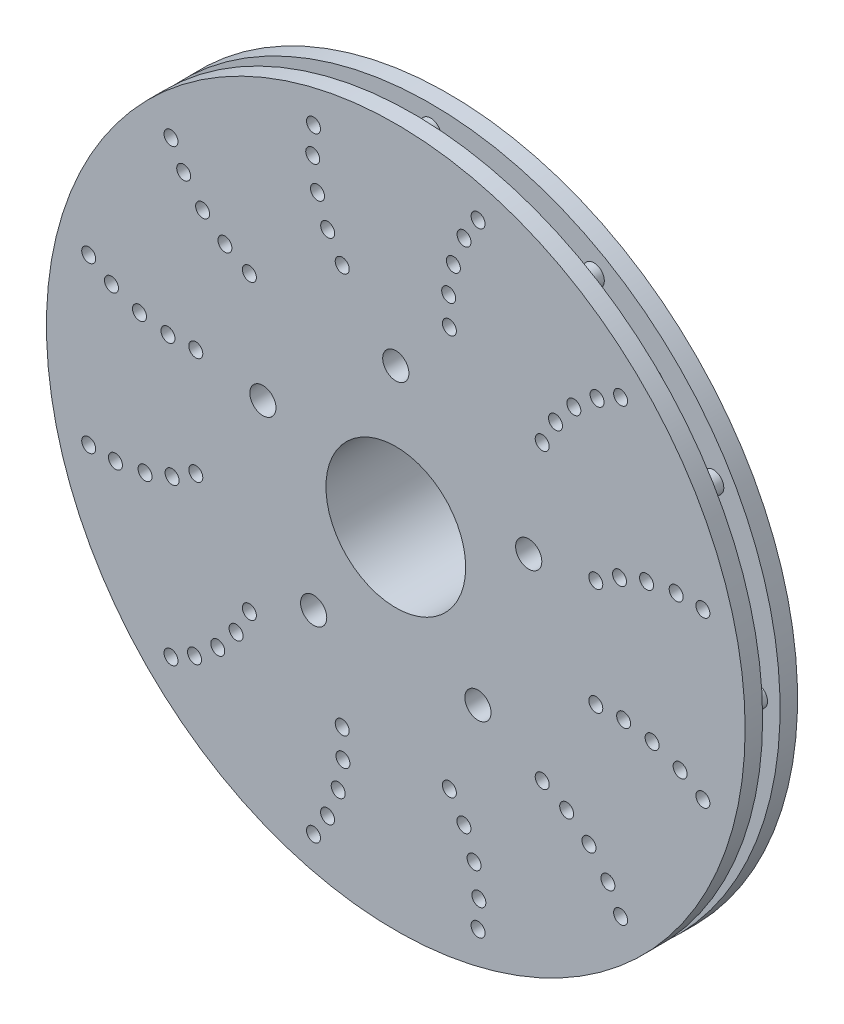
from build123d import *

# Parameters (mm, degrees)
SKETCH2_R           = 60.325
SKETCH2_R_2         = 25.4
SKETCH2_R_3         = 4.7625
BOSS_EXTRUDE1_DEPTH = 50.8
SKETCH4_R           = 127
SKETCH4_R_2         = 60.325
BOSS_EXTRUDE2_DEPTH = 6.35
BOSS_EXTRUDE3_DEPTH = 6.35
SKETCH6_R           = 127
SKETCH6_R_2         = 66.675
BOSS_EXTRUDE4_DEPTH = 6.35
SKETCH7_R           = 2.54
CUT_EXTRUDE1_DEPTH  = 84.836


with BuildPart() as part:
    # Sketch2 → Boss-Extrude1 (new body)
    with BuildSketch(Plane.XY):
        with Locations((-45.113025794, 24.007516651)):
            Circle(SKETCH2_R)
        with Locations((-45.113025794, 24.007516651)):
            Circle(SKETCH2_R_2, mode=Mode.SUBTRACT)
        with Locations((3.200645234, 39.705579965)):
            Circle(SKETCH2_R_3, mode=Mode.SUBTRACT)
        with Locations((-45.113025794, 74.807516651)):
            Circle(SKETCH2_R_3, mode=Mode.SUBTRACT)
        with Locations((-15.253534977, -17.090546664)):
            Circle(SKETCH2_R_3, mode=Mode.SUBTRACT)
        with Locations((-74.97251661, -17.090546664)):
            Circle(SKETCH2_R_3, mode=Mode.SUBTRACT)
        with Locations((-93.426696822, 39.705579965)):
            Circle(SKETCH2_R_3, mode=Mode.SUBTRACT)
    extrude(amount=BOSS_EXTRUDE1_DEPTH)

    # Sketch4 → Boss-Extrude2 (add)
    with BuildSketch(Plane.XY.offset(50.8)):
        with Locations((-45.113025794, 24.007516651)):
            Circle(SKETCH4_R)
        with Locations((-45.113025794, 24.007516651)):
            Circle(SKETCH4_R_2, mode=Mode.SUBTRACT)
    extrude(amount=-BOSS_EXTRUDE2_DEPTH)

    # Sketch5 → Boss-Extrude3 (add)
    with BuildSketch(Plane(origin=(0, 0, 44.45), x_dir=(-1, 0, 0), z_dir=(0, 0, -1))):
        with BuildLine():
            Line((101.143917866, 128.642816244), (80.279811605, 92.505124145))
            ThreePointArc((80.279811605, 92.505124145), (81.668319408, 87.323142476), (86.850301077, 88.71165028))
            Line((86.850301077, 88.71165028), (107.714407338, 124.849342378))
            ThreePointArc((107.714407338, 124.849342378), (106.325899535, 130.031324047), (101.143917866, 128.642816244))
        make_face()
        with BuildLine():
            Line((48.90649966, 142.639790267), (48.90649966, 100.911577745))
            ThreePointArc((48.90649966, 100.911577745), (45.113025794, 97.118103879), (41.319551928, 100.911577745))
            Line((41.319551928, 100.911577745), (41.319551928, 142.639790267))
            ThreePointArc((41.319551928, 142.639790267), (45.113025794, 146.433264132), (48.90649966, 142.639790267))
        make_face()
        with BuildLine():
            Line((145.954851521, 86.608898195), (109.817159423, 65.744791934))
            ThreePointArc((109.817159423, 65.744791934), (108.428651619, 60.562810265), (113.610633289, 59.174302461))
            Line((113.610633289, 59.174302461), (149.748325387, 80.038408722))
            ThreePointArc((149.748325387, 80.038408722), (151.13683319, 85.220390391), (145.954851521, 86.608898195))
        make_face()
        with BuildLine():
            Line((163.74529941, 27.800990516), (122.017086888, 27.800990516))
            ThreePointArc((122.017086888, 27.800990516), (118.223613022, 24.007516651), (122.017086888, 20.214042785))
            Line((122.017086888, 20.214042785), (163.74529941, 20.214042785))
            ThreePointArc((163.74529941, 20.214042785), (167.538773276, 24.007516651), (163.74529941, 27.800990516))
        make_face()
        with BuildLine():
            Line((149.748325387, -32.023375421), (113.610633289, -11.15926916))
            ThreePointArc((113.610633289, -11.15926916), (108.428651619, -12.547776964), (109.817159423, -17.729758633))
            Line((109.817159423, -17.729758633), (145.954851521, -38.593864894))
            ThreePointArc((145.954851521, -38.593864894), (151.13683319, -37.20535709), (149.748325387, -32.023375421))
        make_face()
        with BuildLine():
            Line((107.714407338, -76.834309077), (86.850301077, -40.696616978))
            ThreePointArc((86.850301077, -40.696616978), (81.668319408, -39.308109175), (80.279811605, -44.490090844))
            Line((80.279811605, -44.490090844), (101.143917866, -80.627782943))
            ThreePointArc((101.143917866, -80.627782943), (106.325899535, -82.016290746), (107.714407338, -76.834309077))
        make_face()
        with BuildLine():
            Line((48.90649966, -94.624756966), (48.90649966, -52.896544444))
            ThreePointArc((48.90649966, -52.896544444), (45.113025794, -49.103070578), (41.319551928, -52.896544444))
            Line((41.319551928, -52.896544444), (41.319551928, -94.624756966))
            ThreePointArc((41.319551928, -94.624756966), (45.113025794, -98.418230831), (48.90649966, -94.624756966))
        make_face()
        with BuildLine():
            Line((-10.917866278, -80.627782943), (9.946239983, -44.490090844))
            ThreePointArc((9.946239983, -44.490090844), (8.55773218, -39.308109175), (3.375750511, -40.696616978))
            Line((3.375750511, -40.696616978), (-17.48835575, -76.834309077))
            ThreePointArc((-17.48835575, -76.834309077), (-16.099847947, -82.016290746), (-10.917866278, -80.627782943))
        make_face()
        with BuildLine():
            Line((-55.728799934, -38.593864894), (-19.591107835, -17.729758633))
            ThreePointArc((-19.591107835, -17.729758633), (-18.202600032, -12.547776964), (-23.384581701, -11.15926916))
            Line((-23.384581701, -11.15926916), (-59.522273799, -32.023375421))
            ThreePointArc((-59.522273799, -32.023375421), (-60.910781603, -37.20535709), (-55.728799934, -38.593864894))
        make_face()
        with BuildLine():
            Line((-73.519247822, 20.214042785), (-31.7910353, 20.214042785))
            ThreePointArc((-31.7910353, 20.214042785), (-27.997561435, 24.007516651), (-31.7910353, 27.800990516))
            Line((-31.7910353, 27.800990516), (-73.519247822, 27.800990516))
            ThreePointArc((-73.519247822, 27.800990516), (-77.312721688, 24.007516651), (-73.519247822, 20.214042785))
        make_face()
        with BuildLine():
            Line((-59.522273799, 80.038408722), (-23.384581701, 59.174302461))
            ThreePointArc((-23.384581701, 59.174302461), (-18.202600032, 60.562810265), (-19.591107835, 65.744791934))
            Line((-19.591107835, 65.744791934), (-55.728799934, 86.608898195))
            ThreePointArc((-55.728799934, 86.608898195), (-60.910781603, 85.220390391), (-59.522273799, 80.038408722))
        make_face()
        with BuildLine():
            Line((-17.48835575, 124.849342378), (3.375750511, 88.71165028))
            ThreePointArc((3.375750511, 88.71165028), (8.55773218, 87.323142476), (9.946239983, 92.505124145))
            Line((9.946239983, 92.505124145), (-10.917866278, 128.642816244))
            ThreePointArc((-10.917866278, 128.642816244), (-16.099847947, 130.031324047), (-17.48835575, 124.849342378))
        make_face()
    extrude(amount=BOSS_EXTRUDE3_DEPTH)

    # Sketch6 → Boss-Extrude4 (add)
    with BuildSketch(Plane(origin=(0, 0, 38.1), x_dir=(-1, 0, 0), z_dir=(0, 0, -1))):
        with Locations((45.113025794, 24.007516651)):
            Circle(SKETCH6_R)
        with Locations((45.113025794, 24.007516651)):
            Circle(SKETCH6_R_2, mode=Mode.SUBTRACT)
    extrude(amount=BOSS_EXTRUDE4_DEPTH)

    # Sketch7 → Cut-Extrude1 (cut)
    with BuildSketch(Plane(origin=(0, 0, 31.75), x_dir=(-1, 0, 0), z_dir=(0, 0, -1))):
        with Locations((64.593155632, 96.708350945)):
            Circle(SKETCH7_R)
        with Locations((15.200842825, 135.641303255)):
            Circle(SKETCH7_R)
        with Locations((25.632895956, 96.708350945)):
            Circle(SKETCH7_R)
        with Locations((24.173711218, 117.181469834)):
            Circle(SKETCH7_R)
        with Locations((20.309627222, 127.368239052)):
            Circle(SKETCH7_R)
        with Locations((25.895195632, 106.825591916)):
            Circle(SKETCH7_R)
        with Locations((69.878934301, 105.338988804)):
            Circle(SKETCH7_R)
        with Locations((73.566024025, 115.168184366)):
            Circle(SKETCH7_R)
        with Locations((75.313013731, 125.92222729)):
            Circle(SKETCH7_R)
        with Locations((75.025208763, 135.641303255)):
            Circle(SKETCH7_R)
        with Locations((98.33373025, 77.228221107)):
            Circle(SKETCH7_R)
        with Locations((107.226667786, 82.05968341)):
            Circle(SKETCH7_R)
        with Locations((115.334378934, 88.728471603)):
            Circle(SKETCH7_R)
        with Locations((122.224337861, 97.168251115)):
            Circle(SKETCH7_R)
        with Locations((126.83462943, 105.729120286)):
            Circle(SKETCH7_R)
        with Locations((117.813860088, 43.487646489)):
            Circle(SKETCH7_R)
        with Locations((127.93110106, 43.225346813)):
            Circle(SKETCH7_R)
        with Locations((138.286978977, 44.946831226)):
            Circle(SKETCH7_R)
        with Locations((148.473748196, 48.810915222)):
            Circle(SKETCH7_R)
        with Locations((156.746812399, 53.919699619)):
            Circle(SKETCH7_R)
        with Locations((117.813860088, 4.527386812)):
            Circle(SKETCH7_R)
        with Locations((126.444497948, -0.758391856)):
            Circle(SKETCH7_R)
        with Locations((136.27369351, -4.445481581)):
            Circle(SKETCH7_R)
        with Locations((147.027736433, -6.192471287)):
            Circle(SKETCH7_R)
        with Locations((156.746812399, -5.904666318)):
            Circle(SKETCH7_R)
        with Locations((98.33373025, -29.213187806)):
            Circle(SKETCH7_R)
        with Locations((103.165192553, -38.106125341)):
            Circle(SKETCH7_R)
        with Locations((109.833980746, -46.213836489)):
            Circle(SKETCH7_R)
        with Locations((118.273760258, -53.103795417)):
            Circle(SKETCH7_R)
        with Locations((126.83462943, -57.714086985)):
            Circle(SKETCH7_R)
        with Locations((64.593155632, -48.693317644)):
            Circle(SKETCH7_R)
        with Locations((64.330855956, -58.810558615)):
            Circle(SKETCH7_R)
        with Locations((66.05234037, -69.166436533)):
            Circle(SKETCH7_R)
        with Locations((69.916424366, -79.353205751)):
            Circle(SKETCH7_R)
        with Locations((75.025208763, -87.626269954)):
            Circle(SKETCH7_R)
        with Locations((25.632895956, -48.693317644)):
            Circle(SKETCH7_R)
        with Locations((20.347117287, -57.323955503)):
            Circle(SKETCH7_R)
        with Locations((16.660027563, -67.153151065)):
            Circle(SKETCH7_R)
        with Locations((14.913037856, -77.907193989)):
            Circle(SKETCH7_R)
        with Locations((15.200842825, -87.626269954)):
            Circle(SKETCH7_R)
        with Locations((-8.107678662, -29.213187806)):
            Circle(SKETCH7_R)
        with Locations((-17.000616198, -34.044650108)):
            Circle(SKETCH7_R)
        with Locations((-25.108327346, -40.713438302)):
            Circle(SKETCH7_R)
        with Locations((-31.998286274, -49.153217814)):
            Circle(SKETCH7_R)
        with Locations((-36.608577842, -57.714086985)):
            Circle(SKETCH7_R)
        with Locations((-27.5878085, 4.527386812)):
            Circle(SKETCH7_R)
        with Locations((-37.705049472, 4.789686488)):
            Circle(SKETCH7_R)
        with Locations((-48.060927389, 3.068202075)):
            Circle(SKETCH7_R)
        with Locations((-58.247696608, -0.795881921)):
            Circle(SKETCH7_R)
        with Locations((-66.520760811, -5.904666318)):
            Circle(SKETCH7_R)
        with Locations((-27.5878085, 43.487646489)):
            Circle(SKETCH7_R)
        with Locations((-36.21844636, 48.773425157)):
            Circle(SKETCH7_R)
        with Locations((-46.047641922, 52.460514882)):
            Circle(SKETCH7_R)
        with Locations((-56.801684845, 54.207504588)):
            Circle(SKETCH7_R)
        with Locations((-66.520760811, 53.919699619)):
            Circle(SKETCH7_R)
        with Locations((-8.107678662, 77.228221107)):
            Circle(SKETCH7_R)
        with Locations((-12.939140965, 86.121158642)):
            Circle(SKETCH7_R)
        with Locations((-19.607929158, 94.22886979)):
            Circle(SKETCH7_R)
        with Locations((-28.04770867, 101.118828718)):
            Circle(SKETCH7_R)
        with Locations((-36.608577842, 105.729120286)):
            Circle(SKETCH7_R)
    extrude(amount=-CUT_EXTRUDE1_DEPTH, mode=Mode.SUBTRACT)


solid = part.part
